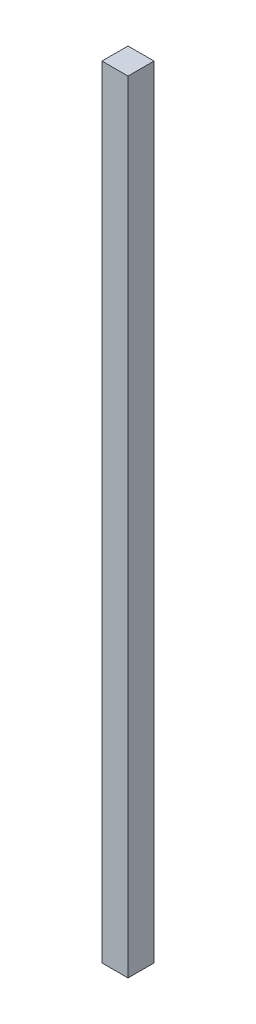
from build123d import *

# Parameters (mm, degrees)
SKETCH1_W           = 101.6
SKETCH1_H           = 101.6
BOSS_EXTRUDE1_DEPTH = 3048


with BuildPart() as part:
    # Sketch1 → Boss-Extrude1 (new body)
    with BuildSketch(Plane(origin=(0, 0, 0), x_dir=(1, 0, 0), z_dir=(0, 1, 0))):
        Rectangle(SKETCH1_W, SKETCH1_H)
    extrude(amount=BOSS_EXTRUDE1_DEPTH)


solid = part.part
